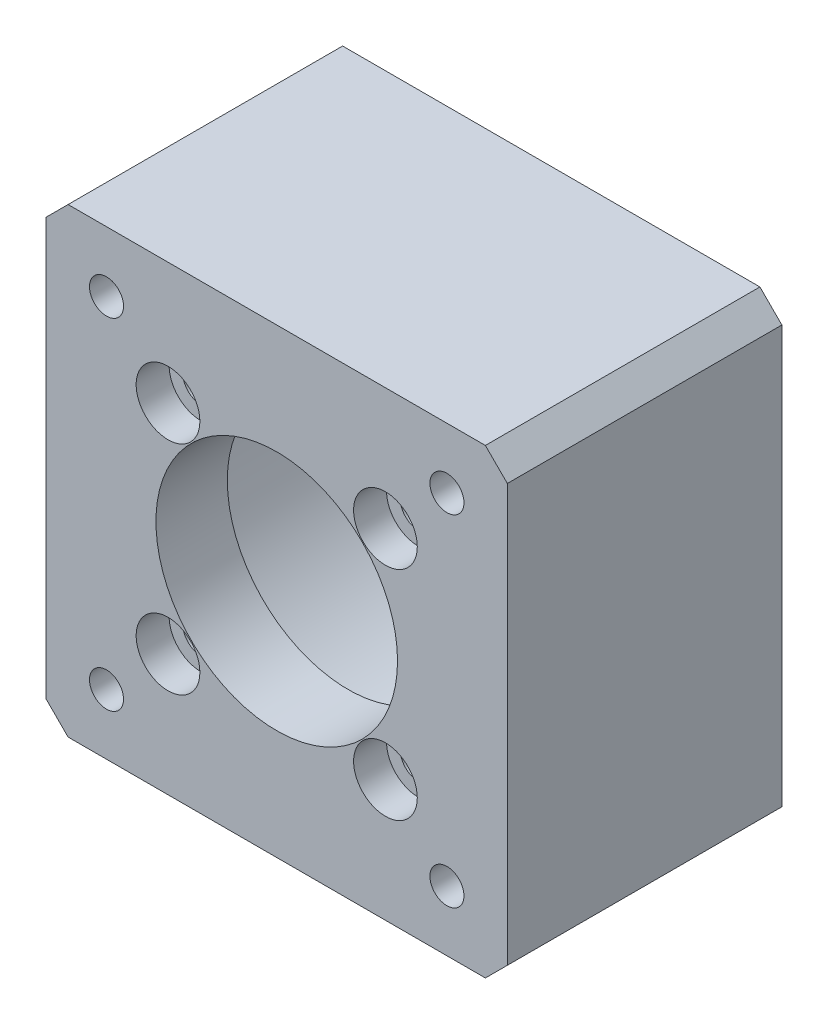
from build123d import *

# Parameters (mm, degrees)
SKETCH1_W           = 42
SKETCH1_H           = 42
SKETCH1_R           = 1.55
BOSS_EXTRUDE1_DEPTH = 25
SKETCH2_R           = 1.65
SKETCH2_R_2         = 11
CUT_EXTRUDE1_DEPTH  = 25
SKETCH3_R           = 2.9
CUT_EXTRUDE2_DEPTH  = 3
CHAMFER1_SIZE       = 2
SKETCH4_R           = 18.15
CUT_EXTRUDE3_DEPTH  = 18.5
CUT_EXTRUDE_1_DEPTH = 4


with BuildPart() as part:
    # Sketch1 → Boss-Extrude1 (new body)
    with BuildSketch(Plane.XY):
        Rectangle(SKETCH1_W, SKETCH1_H)
        with Locations((-15.5, 15.5)):
            Circle(SKETCH1_R, mode=Mode.SUBTRACT)
        with Locations((15.5, 15.5)):
            Circle(SKETCH1_R, mode=Mode.SUBTRACT)
        with Locations((15.5, -15.5)):
            Circle(SKETCH1_R, mode=Mode.SUBTRACT)
        with Locations((-15.5, -15.5)):
            Circle(SKETCH1_R, mode=Mode.SUBTRACT)
    extrude(amount=BOSS_EXTRUDE1_DEPTH)

    # Sketch2 → Cut-Extrude1 (cut)
    with BuildSketch(Plane.XY.offset(25)):
        with Locations((9.899494937, 9.899494937)):
            Circle(SKETCH2_R)
        with Locations((9.899494937, -9.899494937)):
            Circle(SKETCH2_R)
        with Locations((-9.899494937, -9.899494937)):
            Circle(SKETCH2_R)
        with Locations((-9.899494937, 9.899494937)):
            Circle(SKETCH2_R)
        Circle(SKETCH2_R_2)
    extrude(amount=-CUT_EXTRUDE1_DEPTH, mode=Mode.SUBTRACT)

    # Sketch3 → Cut-Extrude2 (cut)
    with BuildSketch(Plane.XY.offset(25)):
        with Locations((9.899494937, 9.899494937)):
            Circle(SKETCH3_R)
        with Locations((9.899494937, -9.899494937)):
            Circle(SKETCH3_R)
        with Locations((-9.899494937, -9.899494937)):
            Circle(SKETCH3_R)
        with Locations((-9.899494937, 9.899494937)):
            Circle(SKETCH3_R)
    extrude(amount=-CUT_EXTRUDE2_DEPTH, mode=Mode.SUBTRACT)

    # Chamfer1
    chamfer1_edges = [part.edges().sort_by_distance(p)[0] for p in [
        (21, -21, 12.5),
        (-21, -21, 12.5),
        (-21, 21, 12.5),
        (21, 21, 12.5),
    ]]
    chamfer(chamfer1_edges, length=CHAMFER1_SIZE)

    # Sketch4 → Cut-Extrude3 (cut)
    with BuildSketch(Plane(origin=(0, 0, 0), x_dir=(-1, 0, 0), z_dir=(0, 0, -1))):
        Circle(SKETCH4_R)
    extrude(amount=-CUT_EXTRUDE3_DEPTH, mode=Mode.SUBTRACT)

    # 草图1 → 切除-拉伸1 (cut)
    with BuildSketch(Plane.XY):
        Polygon((-15.5, 12.209103466), (-12.65, 13.854551733), (-12.65, 17.145448267), (-15.5, 18.790896534), (-18.35, 17.145448267), (-18.35, 13.854551733), align=None)
        Polygon((15.5, -12.209103466), (12.65, -13.854551733), (12.65, -17.145448267), (15.5, -18.790896534), (18.35, -17.145448267), (18.35, -13.854551733), align=None)
        Polygon((15.5, 18.790896534), (12.65, 17.145448267), (12.65, 13.854551733), (15.5, 12.209103466), (18.35, 13.854551733), (18.35, 17.145448267), align=None)
        Polygon((-15.5, -12.209103466), (-18.35, -13.854551733), (-18.35, -17.145448267), (-15.5, -18.790896534), (-12.65, -17.145448267), (-12.65, -13.854551733), align=None)
    extrude(amount=CUT_EXTRUDE_1_DEPTH, mode=Mode.SUBTRACT)


solid = part.part
